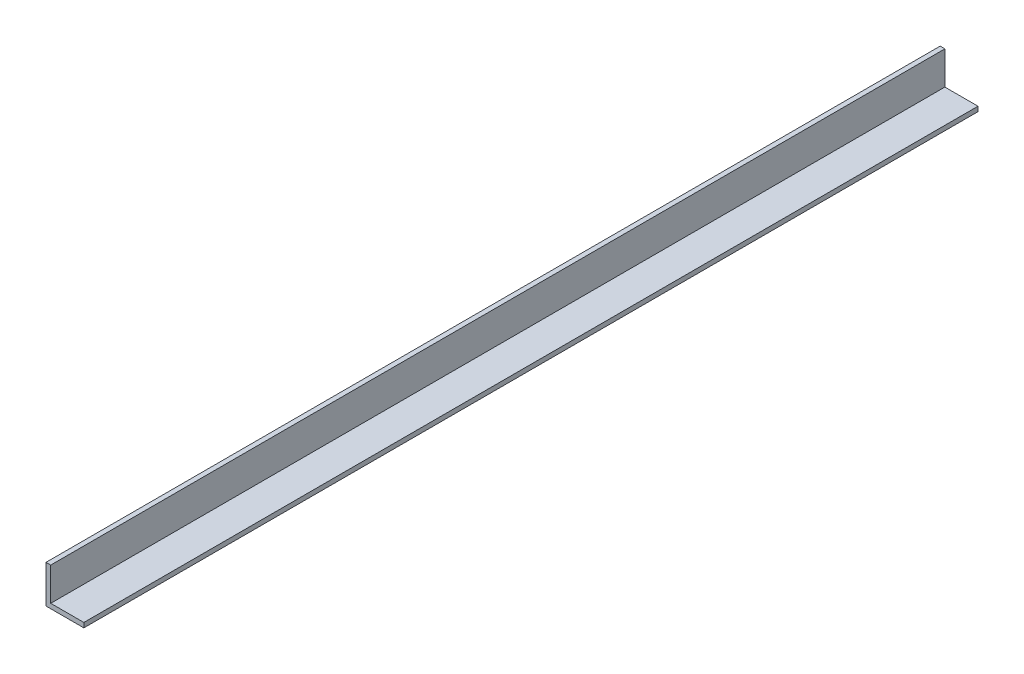
from build123d import *

# Parameters (mm, degrees)
BOSS_EXTRUDE1_DEPTH = 1219.2
FILLET1_R           = 0.4064
SKETCH4_W           = 1838.4
SKETCH4_H           = 103.278519729
CUT_EXTRUDE1_DEPTH  = 60
SKETCH5_W           = 2.838427027
SKETCH5_H           = 1.970979722
CUT_EXTRUDE2_DEPTH  = 700


with BuildPart() as part:
    # Sketch3 → Boss-Extrude1 (new, symmetric)
    with BuildSketch(Plane.XY):
        Polygon((3.175, 25.4), (0, 25.4), (0, 0), (25.4, 0), (25.4, 3.175), (3.175, 3.175), align=None)
    extrude(amount=BOSS_EXTRUDE1_DEPTH, both=True)

    # Fillet1
    fillet1_edges = [part.edges().sort_by_distance(p)[0] for p in [
        (3.175, 3.175, 0),
    ]]
    fillet(fillet1_edges, radius=FILLET1_R)

    # Sketch4 → Cut-Extrude1 (cut)
    with BuildSketch(Plane.ZY):
        with Locations((-300, -26.239259864)):
            Rectangle(SKETCH4_W, SKETCH4_H)
    extrude(amount=-CUT_EXTRUDE1_DEPTH, mode=Mode.SUBTRACT)

    # Sketch5 → Cut-Extrude2 (cut)
    with BuildSketch(Plane(origin=(0, 0, 619.2), x_dir=(-1, 0, 0), z_dir=(0, 0, -1))):
        with Locations((-4.594213514, 4.160489861)):
            Rectangle(SKETCH5_W, SKETCH5_H)
    extrude(amount=-CUT_EXTRUDE2_DEPTH, mode=Mode.SUBTRACT)


solid = part.part
